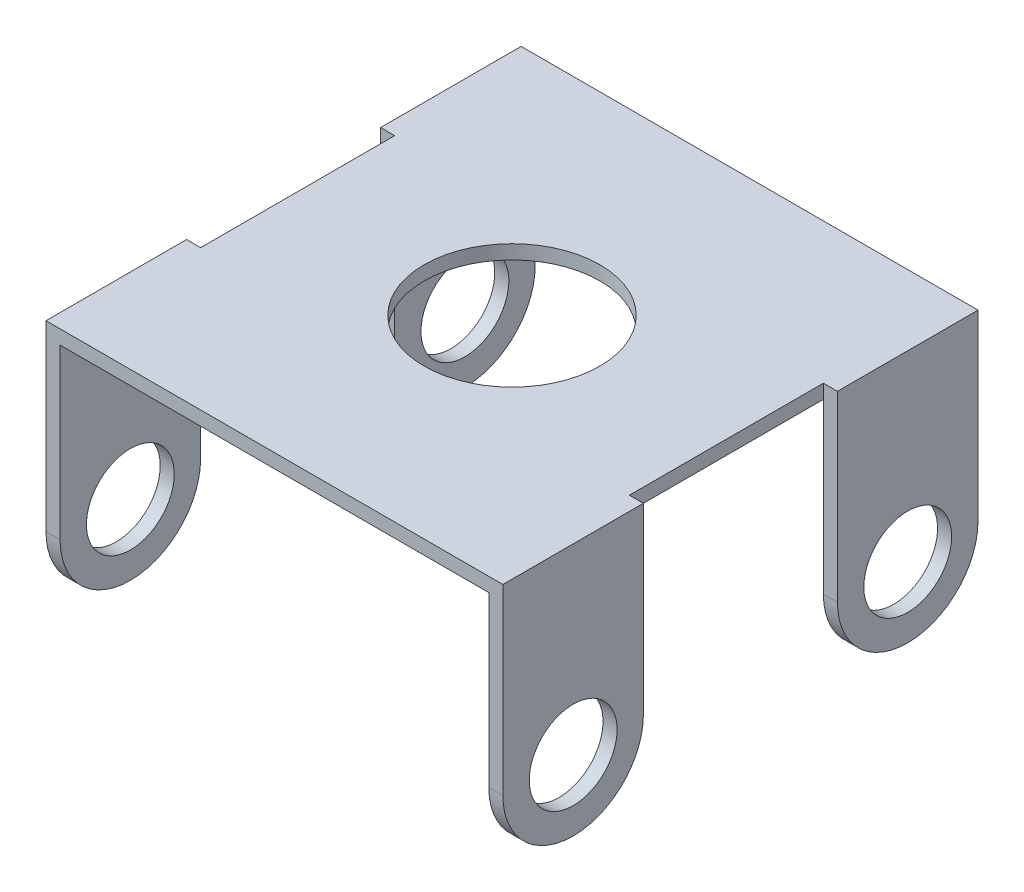
from build123d import *

# Parameters (mm, degrees)
SKETCH1_W               = 38.735
SKETCH1_H               = 42.926
BOSS_EXTRUDE1_DEPTH     = 1.27
SKETCH5_R               = 3.96875
SKETCH5_W               = 12.7
SKETCH5_H               = 1.27
BOSS_EXTRUDE3_DEPTH     = 1.27
MIRROR2_COPY_1_SKETCH_R = 3.96875
MIRROR2_COPY_1_SKETCH_W = 12.7
MIRROR2_COPY_1_SKETCH_H = 1.27
MIRROR2_COPY_1_DEPTH    = 1.27
SKETCH6_R               = 7.9375
CUT_EXTRUDE1_DEPTH      = 2.27
CUT_EXTRUDE1_DEPTH_BACK = 22.59


with BuildPart() as part:
    # Sketch1 → Boss-Extrude1 (new body)
    with BuildSketch(Plane(origin=(0, 0, 0), x_dir=(1, 0, 0), z_dir=(0, 1, 0))):
        Rectangle(SKETCH1_W, SKETCH1_H)
    extrude(amount=BOSS_EXTRUDE1_DEPTH)

    # Sketch5 → Boss-Extrude3 (add)
    with BuildSketch(Plane(origin=(19.3675, 0, 0), x_dir=(0, 0, -1), z_dir=(1, 0, 0))):
        with BuildLine():
            Line((-8.763, 0), (-21.463, 0))
            Line((-21.463, 0), (-21.463, -15.24))
            ThreePointArc((-21.463, -15.24), (-15.113, -21.59), (-8.763, -15.24))
            Line((-8.763, -15.24), (-8.763, 0))
        make_face()
        with Locations((-15.113, -15.24)):
            Circle(SKETCH5_R, mode=Mode.SUBTRACT)
        with Locations((-15.113, 0.635)):
            Rectangle(SKETCH5_W, SKETCH5_H)
    boss_extrude3 = extrude(amount=BOSS_EXTRUDE3_DEPTH)

    # Mirror1: Boss-Extrude3 across plane
    add(boss_extrude3.mirror(Plane.XY))

    # Mirror2: Boss-Extrude3 across plane
    add(boss_extrude3.mirror(Plane(origin=(0, 0, 0), x_dir=(0, 0, 1), z_dir=(1, 0, 0))))

    # Mirror2 copy 1 sketch → Mirror2 copy 1 (add)
    with BuildSketch(Plane.ZY.offset(19.3675)):
        with BuildLine():
            Line((-8.763, 0), (-21.463, 0))
            Line((-21.463, 0), (-21.463, -15.24))
            ThreePointArc((-21.463, -15.24), (-15.113, -21.59), (-8.763, -15.24))
            Line((-8.763, -15.24), (-8.763, 0))
        make_face()
        with Locations((-15.113, -15.24)):
            Circle(MIRROR2_COPY_1_SKETCH_R, mode=Mode.SUBTRACT)
        with Locations((-15.113, 0.635)):
            Rectangle(MIRROR2_COPY_1_SKETCH_W, MIRROR2_COPY_1_SKETCH_H)
    extrude(amount=MIRROR2_COPY_1_DEPTH)

    # Sketch6 → Cut-Extrude1 (cut, two sides)
    with BuildSketch(Plane(origin=(0, 0, 0), x_dir=(1, 0, 0), z_dir=(0, 1, 0))) as cut_extrude1_sk:
        Circle(SKETCH6_R)
    extrude(amount=CUT_EXTRUDE1_DEPTH, mode=Mode.SUBTRACT)
    extrude(cut_extrude1_sk.sketch, amount=-CUT_EXTRUDE1_DEPTH_BACK, mode=Mode.SUBTRACT)


solid = part.part
